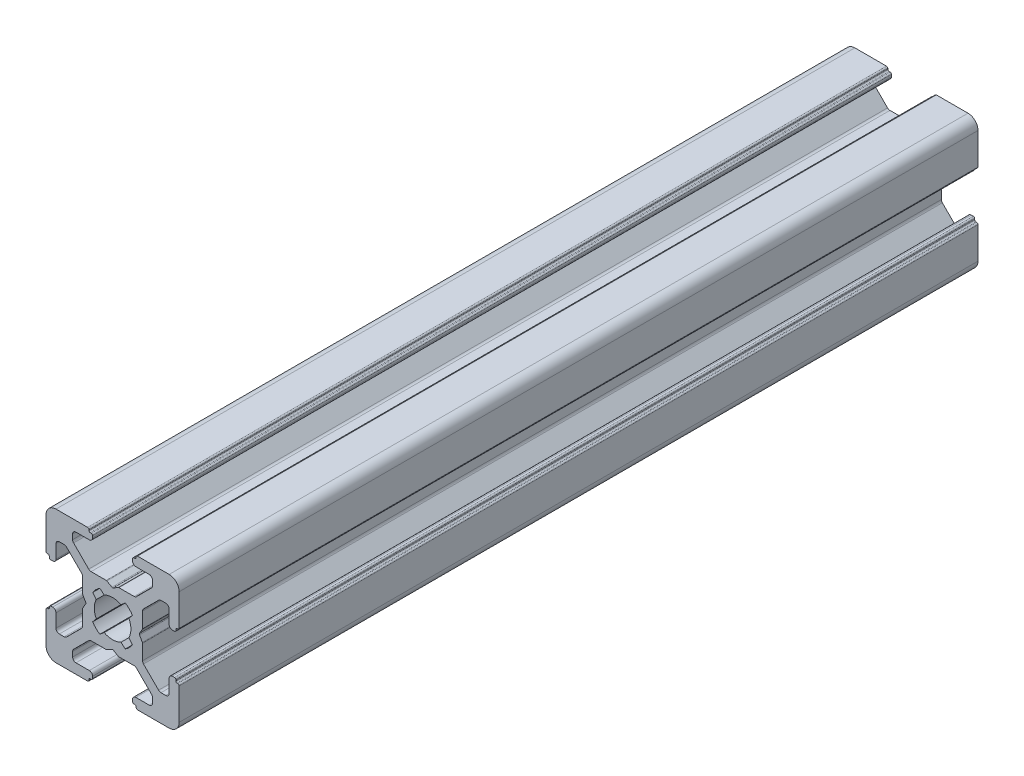
from build123d import *

# Parameters (mm, degrees)
EXTRUDE1_DEPTH = 120


with BuildPart() as part:
    # Sketch1 → Extrude1 (new body)
    with BuildSketch(Plane.XY):
        with BuildLine():
            Line((-3.5, 8.499999673), (-5.500000686, 8.499999673))
            ThreePointArc((-5.500000686, 8.499999673), (-5.853554077, 8.353553064), (-6.000000686, 7.999999673))
            Line((-6.000000686, 7.999999673), (-6.000000686, 7.267766626))
            ThreePointArc((-6.000000686, 7.267766626), (-5.961940448, 7.076424899), (-5.853554059, 6.914213219))
            Line((-5.853554059, 6.914213219), (-3.585787212, 4.646446592))
            ThreePointArc((-3.585787212, 4.646446592), (-3.423575544, 4.538060229), (-3.232233839, 4.5))
            Line((-3.232233839, 4.5), (-0.953590312, 4.5))
            ThreePointArc((-0.953590312, 4.5), (-0.901826505, 4.493185166), (-0.853590316, 4.473205083))
            Line((-0.853590316, 4.473205083), (-0.100000045, 4.038119562))
            ThreePointArc((-0.100000045, 4.038119562), (0, 4.011324632), (0.100000045, 4.038119562))
            Line((0.100000045, 4.038119562), (0.853590316, 4.473205083))
            ThreePointArc((0.853590316, 4.473205083), (0.901826505, 4.493185166), (0.953590312, 4.5))
            Line((0.953590312, 4.5), (3.232233839, 4.5))
            ThreePointArc((3.232233839, 4.5), (3.423575544, 4.538060229), (3.585787212, 4.646446592))
            Line((3.585787212, 4.646446592), (5.853554059, 6.914213219))
            ThreePointArc((5.853554059, 6.914213219), (5.961940448, 7.076424899), (6.000000686, 7.267766626))
            Line((6.000000686, 7.267766626), (6.000000686, 7.999999673))
            ThreePointArc((6.000000686, 7.999999673), (5.853554077, 8.353553064), (5.500000686, 8.499999673))
            Line((5.500000686, 8.499999673), (3.5, 8.499999673))
            ThreePointArc((3.5, 8.499999673), (3.146446609, 8.646446283), (3, 8.999999673))
            Line((3, 8.999999673), (3, 9.3))
            ThreePointArc((3, 9.3), (3.058578644, 9.441421356), (3.2, 9.5))
            Line((3.2, 9.5), (3.350000228, 9.5))
            ThreePointArc((3.350000228, 9.5), (3.491421584, 9.558578644), (3.550000228, 9.7))
            Line((3.550000228, 9.7), (3.550000228, 9.8))
            ThreePointArc((3.550000228, 9.8), (3.608578871, 9.941421356), (3.750000228, 10))
            Line((3.750000228, 10), (8.5, 10))
            ThreePointArc((8.5, 10), (9.560660172, 9.560660172), (10, 8.5))
            Line((10, 8.5), (10, 3.749999605))
            ThreePointArc((10, 3.749999605), (9.941421356, 3.608578248), (9.8, 3.549999605))
            Line((9.8, 3.549999605), (9.699999732, 3.549999605))
            ThreePointArc((9.699999732, 3.549999605), (9.558578376, 3.491420961), (9.499999732, 3.349999605))
            Line((9.499999732, 3.349999605), (9.499999732, 3.2))
            ThreePointArc((9.499999732, 3.2), (9.441421088, 3.058578644), (9.299999732, 3))
            Line((9.299999732, 3), (8.999999732, 3))
            ThreePointArc((8.999999732, 3), (8.646446341, 3.146446609), (8.499999732, 3.5))
            Line((8.499999732, 3.5), (8.499999732, 5.499999605))
            ThreePointArc((8.499999732, 5.499999605), (8.353553123, 5.853552995), (7.999999732, 5.999999605))
            Line((7.999999732, 5.999999605), (7.267766685, 5.999999605))
            ThreePointArc((7.267766685, 5.999999605), (7.076424969, 5.961939371), (6.914213294, 5.853552995))
            Line((6.914213294, 5.853552995), (4.646446398, 3.585786099))
            ThreePointArc((4.646446398, 3.585786099), (4.538060023, 3.423574425), (4.499999789, 3.232232708))
            Line((4.499999789, 3.232232708), (4.499999789, 0.953589302))
            ThreePointArc((4.499999789, 0.953589302), (4.493184953, 0.90182549), (4.473204867, 0.853589297))
            Line((4.473204867, 0.853589297), (4.038119841, 0.099999969))
            ThreePointArc((4.038119841, 0.099999969), (4.011324929, 0), (4.038119841, -0.099999969))
            Line((4.038119841, -0.099999969), (4.473204867, -0.853589297))
            ThreePointArc((4.473204867, -0.853589297), (4.493184953, -0.90182549), (4.499999789, -0.953589302))
            Line((4.499999789, -0.953589302), (4.499999789, -3.232232708))
            ThreePointArc((4.499999789, -3.232232708), (4.538060023, -3.423574425), (4.646446398, -3.585786099))
            Line((4.646446398, -3.585786099), (6.914213294, -5.853552995))
            ThreePointArc((6.914213294, -5.853552995), (7.076424969, -5.961939371), (7.267766685, -5.999999605))
            Line((7.267766685, -5.999999605), (7.999999732, -5.999999605))
            ThreePointArc((7.999999732, -5.999999605), (8.353553123, -5.853552995), (8.499999732, -5.499999605))
            Line((8.499999732, -5.499999605), (8.499999732, -3.5))
            ThreePointArc((8.499999732, -3.5), (8.646446341, -3.146446609), (8.999999732, -3))
            Line((8.999999732, -3), (9.299999732, -3))
            ThreePointArc((9.299999732, -3), (9.441421088, -3.058578644), (9.499999732, -3.2))
            Line((9.499999732, -3.2), (9.499999732, -3.349999605))
            ThreePointArc((9.499999732, -3.349999605), (9.558578376, -3.491420961), (9.699999732, -3.549999605))
            Line((9.699999732, -3.549999605), (9.8, -3.549999605))
            ThreePointArc((9.8, -3.549999605), (9.941421356, -3.608578248), (10, -3.749999605))
            Line((10, -3.749999605), (10, -8.5))
            ThreePointArc((10, -8.5), (9.560660172, -9.560660172), (8.5, -10))
            Line((8.5, -10), (3.750000228, -10))
            ThreePointArc((3.750000228, -10), (3.608578871, -9.941421356), (3.550000228, -9.8))
            Line((3.550000228, -9.8), (3.550000228, -9.7))
            ThreePointArc((3.550000228, -9.7), (3.491421584, -9.558578644), (3.350000228, -9.5))
            Line((3.350000228, -9.5), (3.2, -9.5))
            ThreePointArc((3.2, -9.5), (3.058578644, -9.441421356), (3, -9.3))
            Line((3, -9.3), (3, -8.999999673))
            ThreePointArc((3, -8.999999673), (3.146446609, -8.646446283), (3.5, -8.499999673))
            Line((3.5, -8.499999673), (5.500000686, -8.499999673))
            ThreePointArc((5.500000686, -8.499999673), (5.853554077, -8.353553064), (6.000000686, -7.999999673))
            Line((6.000000686, -7.999999673), (6.000000686, -7.267766626))
            ThreePointArc((6.000000686, -7.267766626), (5.961940448, -7.076424899), (5.853554059, -6.914213219))
            Line((5.853554059, -6.914213219), (3.585787212, -4.646446592))
            ThreePointArc((3.585787212, -4.646446592), (3.423575544, -4.538060229), (3.232233839, -4.5))
            Line((3.232233839, -4.5), (0.953590312, -4.5))
            ThreePointArc((0.953590312, -4.5), (0.901826505, -4.493185166), (0.853590316, -4.473205083))
            Line((0.853590316, -4.473205083), (0.100000045, -4.038119562))
            ThreePointArc((0.100000045, -4.038119562), (0, -4.011324632), (-0.100000045, -4.038119562))
            Line((-0.100000045, -4.038119562), (-0.853590316, -4.473205083))
            ThreePointArc((-0.853590316, -4.473205083), (-0.901826505, -4.493185166), (-0.953590312, -4.5))
            Line((-0.953590312, -4.5), (-3.232233839, -4.5))
            ThreePointArc((-3.232233839, -4.5), (-3.423575544, -4.538060229), (-3.585787212, -4.646446592))
            Line((-3.585787212, -4.646446592), (-5.853554059, -6.914213219))
            ThreePointArc((-5.853554059, -6.914213219), (-5.961940448, -7.076424899), (-6.000000686, -7.267766626))
            Line((-6.000000686, -7.267766626), (-6.000000686, -7.999999673))
            ThreePointArc((-6.000000686, -7.999999673), (-5.853554077, -8.353553064), (-5.500000686, -8.499999673))
            Line((-5.500000686, -8.499999673), (-3.5, -8.499999673))
            ThreePointArc((-3.5, -8.499999673), (-3.146446609, -8.646446283), (-3, -8.999999673))
            Line((-3, -8.999999673), (-3, -9.3))
            ThreePointArc((-3, -9.3), (-3.058578644, -9.441421356), (-3.2, -9.5))
            Line((-3.2, -9.5), (-3.350000228, -9.5))
            ThreePointArc((-3.350000228, -9.5), (-3.491421584, -9.558578644), (-3.550000228, -9.7))
            Line((-3.550000228, -9.7), (-3.550000228, -9.8))
            ThreePointArc((-3.550000228, -9.8), (-3.608578871, -9.941421356), (-3.750000228, -10))
            Line((-3.750000228, -10), (-8.5, -10))
            ThreePointArc((-8.5, -10), (-9.560660172, -9.560660172), (-10, -8.5))
            Line((-10, -8.5), (-10, -3.749999605))
            ThreePointArc((-10, -3.749999605), (-9.941421356, -3.608578248), (-9.8, -3.549999605))
            Line((-9.8, -3.549999605), (-9.699999732, -3.549999605))
            ThreePointArc((-9.699999732, -3.549999605), (-9.558578376, -3.491420961), (-9.499999732, -3.349999605))
            Line((-9.499999732, -3.349999605), (-9.499999732, -3.2))
            ThreePointArc((-9.499999732, -3.2), (-9.441421088, -3.058578644), (-9.299999732, -3))
            Line((-9.299999732, -3), (-8.999999732, -3))
            ThreePointArc((-8.999999732, -3), (-8.646446341, -3.146446609), (-8.499999732, -3.5))
            Line((-8.499999732, -3.5), (-8.499999732, -5.499999605))
            ThreePointArc((-8.499999732, -5.499999605), (-8.353553123, -5.853552995), (-7.999999732, -5.999999605))
            Line((-7.999999732, -5.999999605), (-7.267766685, -5.999999605))
            ThreePointArc((-7.267766685, -5.999999605), (-7.076424969, -5.961939371), (-6.914213294, -5.853552995))
            Line((-6.914213294, -5.853552995), (-4.646446398, -3.585786099))
            ThreePointArc((-4.646446398, -3.585786099), (-4.538060023, -3.423574425), (-4.499999789, -3.232232708))
            Line((-4.499999789, -3.232232708), (-4.499999789, -0.953589302))
            ThreePointArc((-4.499999789, -0.953589302), (-4.493184953, -0.90182549), (-4.473204867, -0.853589297))
            Line((-4.473204867, -0.853589297), (-4.038119841, -0.099999969))
            ThreePointArc((-4.038119841, -0.099999969), (-4.011324929, 0), (-4.038119841, 0.099999969))
            Line((-4.038119841, 0.099999969), (-4.473204867, 0.853589297))
            ThreePointArc((-4.473204867, 0.853589297), (-4.493184953, 0.90182549), (-4.499999789, 0.953589302))
            Line((-4.499999789, 0.953589302), (-4.499999789, 3.232232708))
            ThreePointArc((-4.499999789, 3.232232708), (-4.538060023, 3.423574425), (-4.646446398, 3.585786099))
            Line((-4.646446398, 3.585786099), (-6.914213294, 5.853552995))
            ThreePointArc((-6.914213294, 5.853552995), (-7.076424969, 5.961939371), (-7.267766685, 5.999999605))
            Line((-7.267766685, 5.999999605), (-7.999999732, 5.999999605))
            ThreePointArc((-7.999999732, 5.999999605), (-8.353553123, 5.853552995), (-8.499999732, 5.499999605))
            Line((-8.499999732, 5.499999605), (-8.499999732, 3.5))
            ThreePointArc((-8.499999732, 3.5), (-8.646446341, 3.146446609), (-8.999999732, 3))
            Line((-8.999999732, 3), (-9.299999732, 3))
            ThreePointArc((-9.299999732, 3), (-9.441421088, 3.058578644), (-9.499999732, 3.2))
            Line((-9.499999732, 3.2), (-9.499999732, 3.349999605))
            ThreePointArc((-9.499999732, 3.349999605), (-9.558578376, 3.491420961), (-9.699999732, 3.549999605))
            Line((-9.699999732, 3.549999605), (-9.8, 3.549999605))
            ThreePointArc((-9.8, 3.549999605), (-9.941421356, 3.608578248), (-10, 3.749999605))
            Line((-10, 3.749999605), (-10, 8.5))
            ThreePointArc((-10, 8.5), (-9.560660172, 9.560660172), (-8.5, 10))
            Line((-8.5, 10), (-3.750000228, 10))
            ThreePointArc((-3.750000228, 10), (-3.608578871, 9.941421356), (-3.550000228, 9.8))
            Line((-3.550000228, 9.8), (-3.550000228, 9.7))
            ThreePointArc((-3.550000228, 9.7), (-3.491421584, 9.558578644), (-3.350000228, 9.5))
            Line((-3.350000228, 9.5), (-3.2, 9.5))
            ThreePointArc((-3.2, 9.5), (-3.058578644, 9.441421356), (-3, 9.3))
            Line((-3, 9.3), (-3, 8.999999673))
            ThreePointArc((-3, 8.999999673), (-3.146446609, 8.646446283), (-3.5, 8.499999673))
        make_face()
        with BuildLine():
            Line((-1.258185436, 2.445295362), (-1.91389502, 2.989640962))
            ThreePointArc((-1.91389502, 2.989640962), (-2.511737261, 2.508410485), (-2.992174953, 1.909930962))
            Line((-2.992174953, 1.909930962), (-2.445295423, 1.258185317))
            ThreePointArc((-2.445295423, 1.258185317), (-2.75, 0), (-2.445295423, -1.258185317))
            Line((-2.445295423, -1.258185317), (-2.992174953, -1.909930962))
            ThreePointArc((-2.992174953, -1.909930962), (-2.511737261, -2.508410485), (-1.91389502, -2.989640962))
            Line((-1.91389502, -2.989640962), (-1.258185436, -2.445295362))
            ThreePointArc((-1.258185436, -2.445295362), (0, -2.75), (1.258185436, -2.445295362))
            Line((1.258185436, -2.445295362), (1.91389502, -2.989640962))
            ThreePointArc((1.91389502, -2.989640962), (2.511737261, -2.508410485), (2.992174953, -1.909930962))
            Line((2.992174953, -1.909930962), (2.445295423, -1.258185317))
            ThreePointArc((2.445295423, -1.258185317), (2.75, 0), (2.445295423, 1.258185317))
            Line((2.445295423, 1.258185317), (2.992174953, 1.909930962))
            ThreePointArc((2.992174953, 1.909930962), (2.511737261, 2.508410485), (1.91389502, 2.989640962))
            Line((1.91389502, 2.989640962), (1.258185436, 2.445295362))
            ThreePointArc((1.258185436, 2.445295362), (0, 2.75), (-1.258185436, 2.445295362))
        make_face(mode=Mode.SUBTRACT)
    extrude(amount=EXTRUDE1_DEPTH)


solid = part.part
